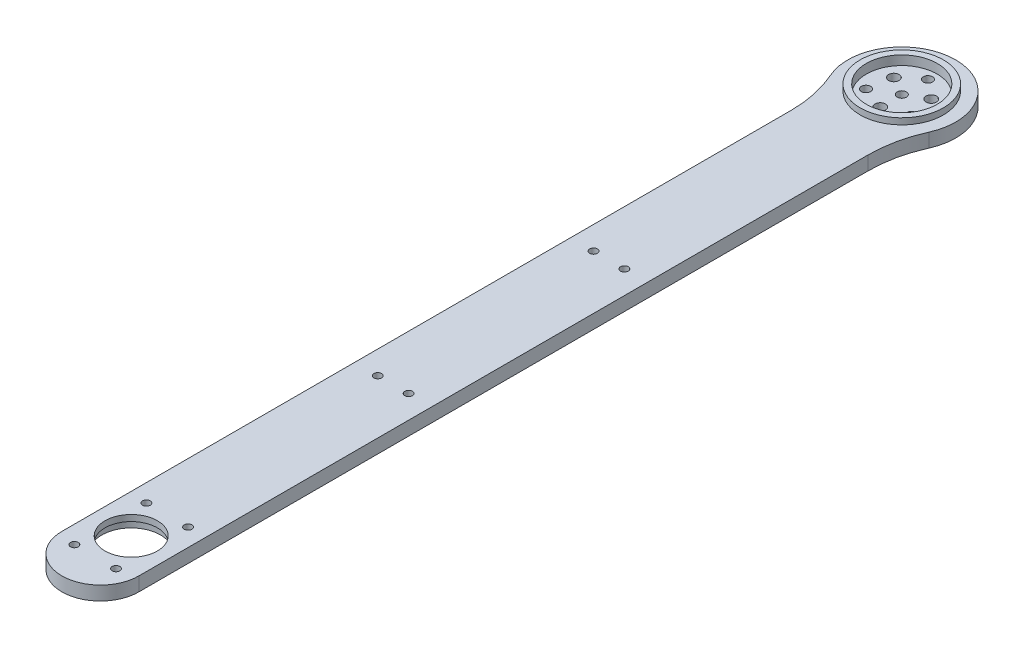
from build123d import *

# Parameters (mm, degrees)
EXTRUDE_1_DEPTH              = 9
SKETCH_3_R                   = 13.5
EXTRUDE_2_DEPTH              = 2
EXTRUDE_START                = 3
SKETCH_4_R                   = 13.5
EXTRUDE_3_DEPTH              = 3
SKETCH_5_R                   = 9.5
CUT_EXTRUDE_2_DEPTH          = 274.324898244
HOLE_WIZARD_M3_1_D           = 3.4
HOLE_WIZARD_M3_1_CBORE_D     = 6.5
HOLE_WIZARD_M3_1_CBORE_DEPTH = 3.4
PATTERN_CIRCULAR_1_COUNT     = 3
EXTRUDE_START_2              = 7
SKETCH_11_R                  = 12.5
SKETCH_11_R_2                = 3.25
EXTRUDE_4_DEPTH              = 7
SKETCH_13_R                  = 11.5
CUT_EXTRUDE_3_DEPTH          = 3
FILLET_1_R                   = 40
SKETCH_26_W                  = 65.136073631
SKETCH_26_H                  = 24.89875822
CUT_EXTRUDE_5_DEPTH          = 1111
SKETCH_28_R                  = 9.5
SKETCH_28_R_2                = 8.5
EXTRUDE_5_DEPTH              = 2
HOLE_WIZARD_M3_2_D           = 2.5
PATTERN_LINEAR_1_COUNT       = 3
PATTERN_LINEAR_1_PITCH       = 70
PATTERN_LINEAR_1_COUNT_DIR2  = 2
PATTERN_LINEAR_1_PITCH_DIR2  = 10
HOLE_WIZARD_M3_3_D           = 2.5
PATTERN_CIRCULAR_4_COUNT     = 6
EXTRUDE_START_3              = -4.5
SKETCH_44_R                  = 1.25
EXTRUDE_6_DEPTH              = 4.5
F_3_0MM_2_D                  = 3
F_3_0MM_2_DEPTH              = 5
F_3_0MM_2_TIP                = 0.901290929
PATTERN_CIRCULAR_5_COUNT     = 3


with BuildPart() as part:
    # 스케치1 → 보스-돌출1 (new body)
    with BuildSketch(Plane(origin=(0, 0, 0), x_dir=(1, 0, 0), z_dir=(0, 1, 0))):
        with BuildLine():
            Line((-12.5, -260), (-12.5, -12.247448714))
            ThreePointArc((-12.5, -12.247448714), (0, 17.5), (12.5, -12.247448714))
            Line((12.5, -12.247448714), (12.5, -260))
            ThreePointArc((12.5, -260), (0, -272.5), (-12.5, -260))
        make_face()
    extrude(amount=EXTRUDE_1_DEPTH)

    # 스케치3 → 보스-돌출2 (add)
    with BuildSketch(Plane(origin=(0, 9, 0), x_dir=(1, 0, 0), z_dir=(0, 1, 0))):
        Circle(SKETCH_3_R)
    extrude(amount=EXTRUDE_2_DEPTH)

    # 스케치4 → 보스-돌출3 (add)
    with BuildSketch(Plane.XZ.offset(EXTRUDE_START)):
        Circle(SKETCH_4_R)
    extrude(amount=-EXTRUDE_3_DEPTH)

    # 스케치5 → 컷-돌출2 (cut, through all)
    with BuildSketch(Plane(origin=(0, 9, 0), x_dir=(1, 0, 0), z_dir=(0, 1, 0))):
        with Locations((0, -250)):
            Circle(SKETCH_5_R)
    extrude(amount=-CUT_EXTRUDE_2_DEPTH, mode=Mode.SUBTRACT)

    # M3 육각 소켓 머리 캡 나사용 카운터보어1 (through all)
    with Locations(Plane(origin=(0, -3, 0), x_dir=(-1, 0, 0), z_dir=(0, -1, 0))):
        with Locations((0, -7)):
            hole_wizard_m3_1 = CounterBoreHole(HOLE_WIZARD_M3_1_D / 2, HOLE_WIZARD_M3_1_CBORE_D / 2, HOLE_WIZARD_M3_1_CBORE_DEPTH)

    # 원형 패턴1: M3 육각 소켓 머리 캡 나사용 카운터보어1 ×3 about axis
    pattern_circular_1_axis = Axis((0, 9, 0), (0, -1, 0))
    for i in range(1, PATTERN_CIRCULAR_1_COUNT):
        add(hole_wizard_m3_1.rotate(pattern_circular_1_axis, i * 360 / PATTERN_CIRCULAR_1_COUNT), mode=Mode.SUBTRACT)

    # 스케치11 → 보스-돌출4 (add)
    with BuildSketch(Plane.XZ.offset(3).offset(EXTRUDE_START_2)):
        Circle(SKETCH_11_R)
        with Locations((-6.062177826, -3.5)):
            Circle(SKETCH_11_R_2, mode=Mode.SUBTRACT)
        with Locations((6.062177826, -3.5)):
            Circle(SKETCH_11_R_2, mode=Mode.SUBTRACT)
        with Locations((0, 7)):
            Circle(SKETCH_11_R_2, mode=Mode.SUBTRACT)
    extrude(amount=-EXTRUDE_4_DEPTH)

    # 스케치13 → 컷-돌출3 (cut)
    with BuildSketch(Plane(origin=(0, 11, 0), x_dir=(1, 0, 0), z_dir=(0, 1, 0))):
        Circle(SKETCH_13_R)
    extrude(amount=-CUT_EXTRUDE_3_DEPTH, mode=Mode.SUBTRACT)

    # 필렛1
    fillet_1_edges = [part.edges().sort_by_distance(p)[0] for p in [
        (12.5, 4.5, 12.247448714),
        (-12.5, 4.5, 12.247448714),
    ]]
    fillet(fillet_1_edges, radius=FILLET_1_R)

    # 스케치26 → 컷-돌출5 (cut, symmetric)
    with BuildSketch(Plane.XY):
        with Locations((0.11753139, -7.94937911)):
            Rectangle(SKETCH_26_W, SKETCH_26_H)
    extrude(amount=CUT_EXTRUDE_5_DEPTH, both=True, mode=Mode.SUBTRACT)

    # 스케치28 → 보스-돌출5 (add)
    with BuildSketch(Plane(origin=(0, 9, 0), x_dir=(1, 0, 0), z_dir=(0, 1, 0))):
        with Locations((0, -250)):
            Circle(SKETCH_28_R)
        with Locations((0, -250)):
            Circle(SKETCH_28_R_2, mode=Mode.SUBTRACT)
    extrude(amount=-EXTRUDE_5_DEPTH)

    # M3 탭을 위한 탭 드릴2 (through all)
    with Locations(Plane(origin=(0, 4.5, 0), x_dir=(-1, 0, 0), z_dir=(0, -1, 0))):
        with Locations((5, -25)):
            hole_wizard_m3_2 = Hole(HOLE_WIZARD_M3_2_D / 2)

    # 선형 패턴1: Hole Wizard M3 _ _ _ _2 3 × 2
    with Locations(*[(j * PATTERN_LINEAR_1_PITCH_DIR2, 0, i * PATTERN_LINEAR_1_PITCH) for i in range(PATTERN_LINEAR_1_COUNT) for j in range(PATTERN_LINEAR_1_COUNT_DIR2) if (i, j) != (0, 0)]):
        add(hole_wizard_m3_2, mode=Mode.SUBTRACT)

    # M3 탭을 위한 탭 드릴3 (through all)
    with Locations(Plane(origin=(0, 4.5, 0), x_dir=(-1, 0, 0), z_dir=(0, -1, 0))):
        with Locations((6.75, -261.691342951)):
            hole_wizard_m3_3 = Hole(HOLE_WIZARD_M3_3_D / 2)

    # 원형 패턴4: M3 탭을 위한 탭 드릴3 ×6 about axis, 2 skipped
    pattern_circular_4_axis = Axis((0, -3, 250), (0, 1, 0))
    add([hole_wizard_m3_3.rotate(pattern_circular_4_axis, i * 360 / PATTERN_CIRCULAR_4_COUNT) for i in range(1, PATTERN_CIRCULAR_4_COUNT) if i not in (2, 5)], mode=Mode.SUBTRACT)

    # 스케치44 → 보스-돌출6 (add)
    with BuildSketch(Plane.XZ.offset(-4.5).offset(EXTRUDE_START_3)):
        with Locations((5, 25)):
            Circle(SKETCH_44_R)
        with Locations((-5, 25)):
            Circle(SKETCH_44_R)
    extrude(amount=EXTRUDE_6_DEPTH)

    # Ø3.0mm 맞춤핀 구멍2
    with Locations(Plane(origin=(0, 4.5, 0), x_dir=(-1, 0, 0), z_dir=(0, -1, 0))):
        with Locations((0, 0)):
            Hole(F_3_0MM_2_D / 2, depth=F_3_0MM_2_DEPTH)
            with Locations((0, 0, -(F_3_0MM_2_DEPTH + F_3_0MM_2_TIP / 2))):  # 118° drill point
                Cone(0, F_3_0MM_2_D / 2, F_3_0MM_2_TIP, mode=Mode.SUBTRACT)

    # 스케치50 → Ø3.0mm 맞춤핀 구멍3 (revolve, cut)
    with BuildSketch(Plane(origin=(0, 8, -8.5), x_dir=(0, 0, 1), z_dir=(1, 0, 0))):
        Polygon((0, 0), (0, 5.901290929), (1.5, 5), (1.5, 0), align=None)
    f_3_0mm_3 = revolve(axis=Axis((0, 14.35, -8.5), (0, -1, 0)), mode=Mode.SUBTRACT)

    # 원형 패턴5: Ø3.0mm 맞춤핀 구멍3 ×3 about axis
    pattern_circular_5_axis = Axis((0, 11, 0), (0, -1, 0))
    for i in range(1, PATTERN_CIRCULAR_5_COUNT):
        add(f_3_0mm_3.rotate(pattern_circular_5_axis, i * 360 / PATTERN_CIRCULAR_5_COUNT), mode=Mode.SUBTRACT)


solid = part.part
